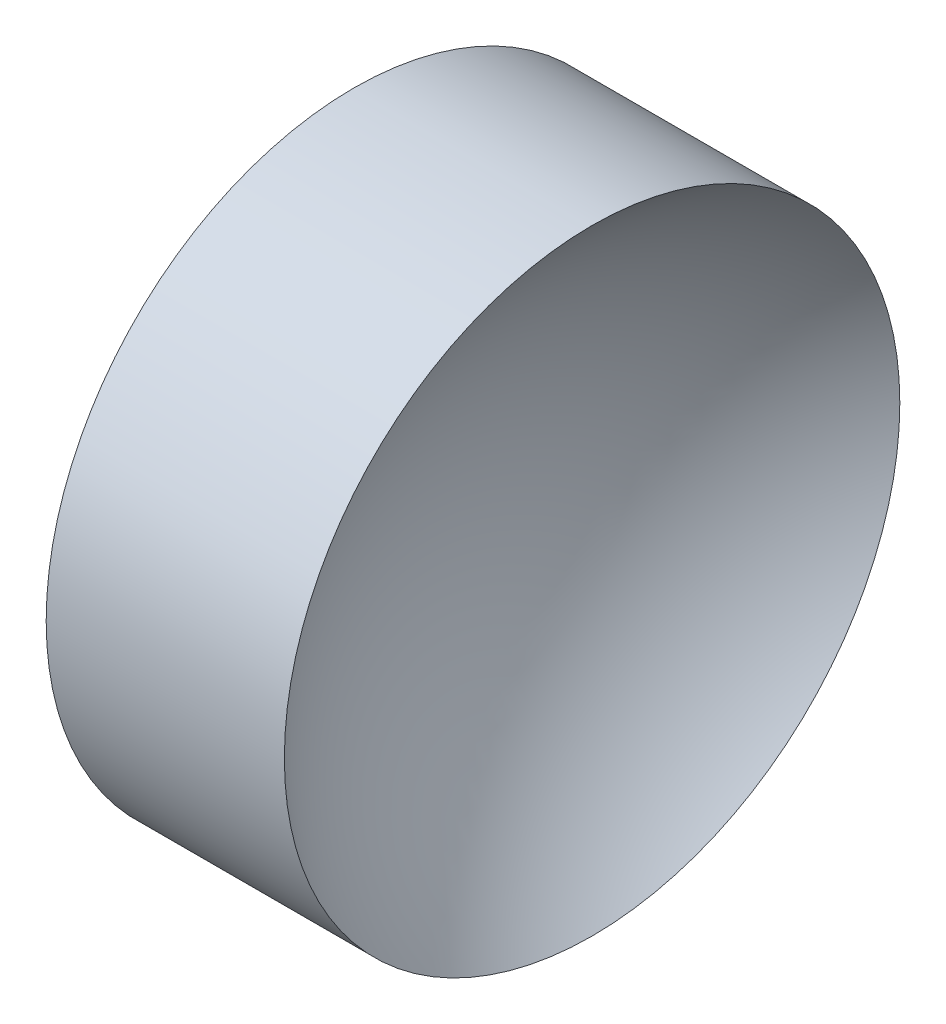
from build123d import *


with BuildPart() as part:
    # 草图1 → 旋转1 (revolve)
    with BuildSketch(Plane.XY, mode=Mode.PRIVATE) as revolve_1_sk:
        with BuildLine():
            Line((44.319585498, 26.089041149), (44.319585498, 31.089041149))
            Line((44.319585498, 31.089041149), (48.189585498, 31.089041149))
            ThreePointArc((48.189585498, 31.089041149), (46.442081262, 28.855668157), (45.819585498, 26.089041149))
            Line((45.819585498, 26.089041149), (44.319585498, 26.089041149))
        make_face()
    revolve(revolve_1_sk.sketch.rotate(Axis((42.449861114, 26.089041149, 0), (1, 0, 0)), 180), axis=Axis((42.449861114, 26.089041149, 0), (1, 0, 0)))  # turned: the seam where the file's is


solid = part.part
